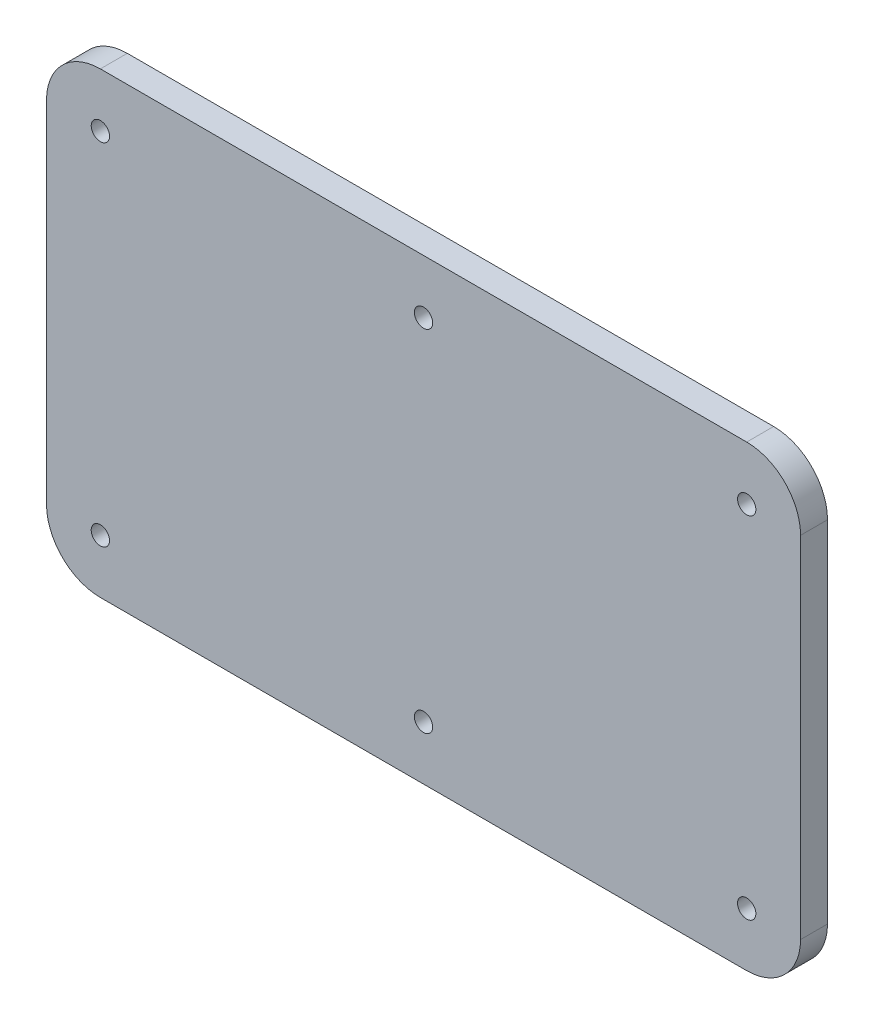
from build123d import *

# Parameters (mm, degrees)
SKETCH1_R           = 1.7
BOSS_EXTRUDE1_DEPTH = 5


with BuildPart() as part:
    # Sketch1 → Boss-Extrude1 (new body)
    with BuildSketch(Plane.XY):
        with BuildLine():
            Line((-60, -42.5), (60, -42.5))
            ThreePointArc((60, -42.5), (67.071067812, -39.571067812), (70, -32.5))
            Line((70, -32.5), (70, 32.5))
            ThreePointArc((70, 32.5), (67.071067812, 39.571067812), (60, 42.5))
            Line((60, 42.5), (-60, 42.5))
            ThreePointArc((-60, 42.5), (-67.071067812, 39.571067812), (-70, 32.5))
            Line((-70, 32.5), (-70, -32.5))
            ThreePointArc((-70, -32.5), (-67.071067812, -39.571067812), (-60, -42.5))
        make_face()
        with Locations((-60, 32.5)):
            Circle(SKETCH1_R, mode=Mode.SUBTRACT)
        with Locations((-60, -32.5)):
            Circle(SKETCH1_R, mode=Mode.SUBTRACT)
        with Locations((60, -32.5)):
            Circle(SKETCH1_R, mode=Mode.SUBTRACT)
        with Locations((60, 32.5)):
            Circle(SKETCH1_R, mode=Mode.SUBTRACT)
        with Locations((0, 32.5)):
            Circle(SKETCH1_R, mode=Mode.SUBTRACT)
        with Locations((0, -32.5)):
            Circle(SKETCH1_R, mode=Mode.SUBTRACT)
    extrude(amount=BOSS_EXTRUDE1_DEPTH)


solid = part.part
